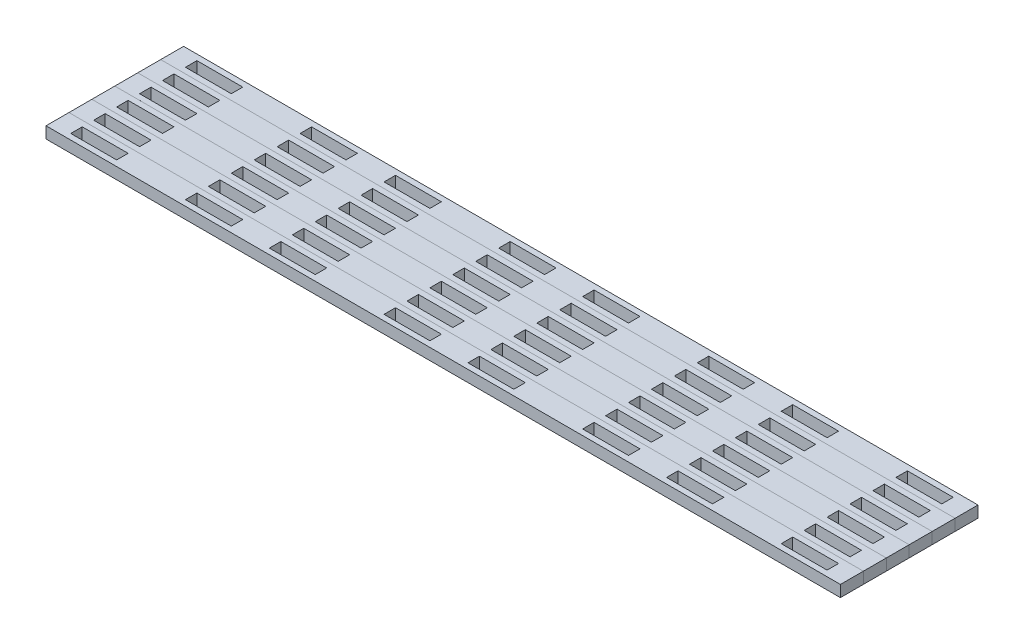
from build123d import *

# Parameters (mm, degrees)
SKETCH1_W           = 439.940905232
SKETCH1_H           = 12.7
BOSS_EXTRUDE1_DEPTH = 6.35
SKETCH2_W           = 25.4
SKETCH2_H           = 6.35
CUT_EXTRUDE1_DEPTH  = 7.35
LPATTERN1_COUNT     = 2
LPATTERN1_PITCH     = 219.970452616
LPATTERN1_COL_COUNT = 2
LPATTERN1_COL_PITCH = 219.970452616
LPATTERN2_COUNT     = 6
LPATTERN2_PITCH     = 12.7


with BuildPart() as part:
    # Sketch1 → Boss-Extrude1 (new body)
    with BuildSketch(Plane(origin=(0, 0, 0), x_dir=(1, 0, 0), z_dir=(0, 1, 0))):
        Rectangle(SKETCH1_W, SKETCH1_H)
    extrude(amount=BOSS_EXTRUDE1_DEPTH)

    # Sketch2 → Cut-Extrude1 (cut, through all)
    with BuildSketch(Plane(origin=(0, 6.35, 0), x_dir=(1, 0, 0), z_dir=(0, 1, 0))):
        with Locations((-23.242613154, 0)):
            Rectangle(SKETCH2_W, SKETCH2_H)
        with Locations((23.242613154, 0)):
            Rectangle(SKETCH2_W, SKETCH2_H)
        with Locations((-86.742613154, 0)):
            Rectangle(SKETCH2_W, SKETCH2_H)
        with Locations((86.742613154, 0)):
            Rectangle(SKETCH2_W, SKETCH2_H)
    cut_extrude1 = extrude(amount=-CUT_EXTRUDE1_DEPTH, mode=Mode.SUBTRACT)

    # LPattern1: Cut-Extrude1 ×2
    with Locations(*[(i * LPATTERN1_PITCH, 0, 0) for i in range(1, LPATTERN1_COUNT)]):
        add(cut_extrude1, mode=Mode.SUBTRACT)

    # LPattern1 col: Cut-Extrude1 ×2
    with Locations(*[(-i * LPATTERN1_COL_PITCH, 0, 0) for i in range(1, LPATTERN1_COL_COUNT)]):
        add(cut_extrude1, mode=Mode.SUBTRACT)


with BuildPart() as lpattern2_1:
    # LPattern2: pattern copy
    add(part.part.moved(Location(Vector(0, 0, 1) * (1 * LPATTERN2_PITCH))))


with BuildPart() as lpattern2_2:
    # LPattern2: pattern copy
    add(part.part.moved(Location(Vector(0, 0, 1) * (2 * LPATTERN2_PITCH))))


with BuildPart() as lpattern2_3:
    # LPattern2: pattern copy
    add(part.part.moved(Location(Vector(0, 0, 1) * (3 * LPATTERN2_PITCH))))


with BuildPart() as lpattern2_4:
    # LPattern2: pattern copy
    add(part.part.moved(Location(Vector(0, 0, 1) * (4 * LPATTERN2_PITCH))))


with BuildPart() as lpattern2_5:
    # LPattern2: pattern copy
    add(part.part.moved(Location(Vector(0, 0, 1) * (5 * LPATTERN2_PITCH))))


solid = Compound([part.part, lpattern2_1.part, lpattern2_2.part, lpattern2_3.part, lpattern2_4.part, lpattern2_5.part])
